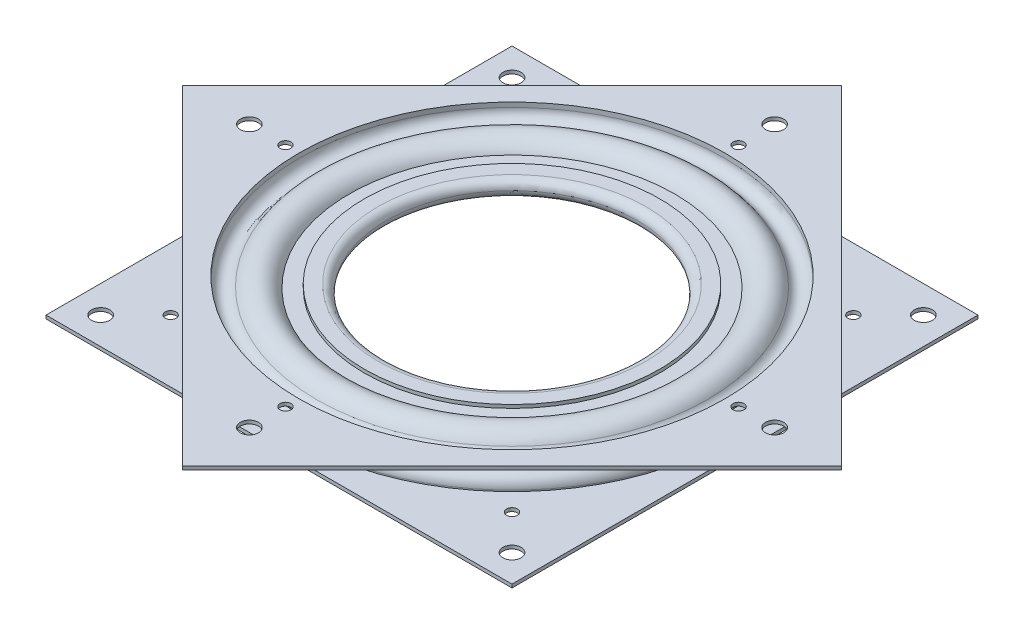
from build123d import *

# Parameters (mm, degrees)
SKETCH2_W                                 = 101.6
SKETCH2_H                                 = 101.6
SKETCH2_R                                 = 46.427290861
EXTRUDE1_DEPTH                            = 0.7366
SKETCH3_R                                 = 46.427290861
EXTRUDE2_DEPTH                            = 0.7366
CIRPATTERN1_COUNT                         = 4
SKETCH5_W                                 = 1.984375
SKETCH5_H                                 = 0.7366
F_5_32_0_156250_DIAMETER_HOLE1_AT_2_COUNT = 2
F_5_32_0_156250_DIAMETER_HOLE1_AT_2_PITCH = 89.6874
F_5_32_0_156250_DIAMETER_HOLE1_AT_3_COUNT = 2
F_5_32_0_156250_DIAMETER_HOLE1_AT_3_PITCH = 89.6874
F_5_32_0_156250_DIAMETER_HOLE1_AT_4_COUNT = 2
F_5_32_0_156250_DIAMETER_HOLE1_AT_4_PITCH = 126.837137454
SKETCH7_W                                 = 1.984375
SKETCH7_H                                 = 8.128
F_5_32_0_156250_DIAMETER_HOLE2_AT_2_COUNT = 2
F_5_32_0_156250_DIAMETER_HOLE2_AT_2_PITCH = 80.9752
F_5_32_0_156250_DIAMETER_HOLE2_AT_3_COUNT = 2
F_5_32_0_156250_DIAMETER_HOLE2_AT_3_PITCH = 114.516226056
F_5_32_0_156250_DIAMETER_HOLE2_AT_4_COUNT = 2
F_5_32_0_156250_DIAMETER_HOLE2_AT_4_PITCH = 80.9752
SKETCH9_W                                 = 1.190625
SKETCH9_H                                 = 0.7366
F_3_32_0_093750_DIAMETER_HOLE1_AT_2_COUNT = 2
F_3_32_0_093750_DIAMETER_HOLE1_AT_2_PITCH = 69.85
F_3_32_0_093750_DIAMETER_HOLE1_AT_3_COUNT = 2
F_3_32_0_093750_DIAMETER_HOLE1_AT_3_PITCH = 98.782817332
F_3_32_0_093750_DIAMETER_HOLE1_AT_4_COUNT = 2
F_3_32_0_093750_DIAMETER_HOLE1_AT_4_PITCH = 69.85
F_3_32_0_093750_DIAMETER_HOLE2_AT_2_COUNT = 2
F_3_32_0_093750_DIAMETER_HOLE2_AT_2_PITCH = 74.422
F_3_32_0_093750_DIAMETER_HOLE2_AT_3_COUNT = 2
F_3_32_0_093750_DIAMETER_HOLE2_AT_3_PITCH = 105.248601739
F_3_32_0_093750_DIAMETER_HOLE2_AT_4_COUNT = 2
F_3_32_0_093750_DIAMETER_HOLE2_AT_4_PITCH = 74.422


with BuildPart() as part:
    # Sketch1 → Revolve-Thin4 (revolve)
    with BuildSketch(Plane.XY, mode=Mode.PRIVATE) as revolve_thin4_sk:
        with BuildLine():
            Line((32.19552446, 1.778), (29.21, 1.778))
            ThreePointArc((29.21, 1.778), (27.432, 0), (29.21, -1.778))
            Line((29.21, -1.778), (35.18104892, -1.778))
            ThreePointArc((35.18104892, -1.778), (38.567175582, -4.788771381), (42.635527241, -2.794))
            ThreePointArc((42.635527241, -2.794), (44.921211161, -1.847238721), (46.427290861, -3.81))
            Line((46.427290861, -3.81), (46.427290861, -4.826))
            Line((46.427290861, -4.826), (50.8, -4.826))
            Line((50.8, -4.826), (50.8, -4.0894))
            Line((50.8, -4.0894), (47.163890861, -4.0894))
            Line((47.163890861, -4.0894), (47.163890861, -3.81))
            ThreePointArc((47.163890861, -3.81), (45.11185727, -1.135737757), (41.997612929, -2.4257))
            ThreePointArc((41.997612929, -2.4257), (38.390625346, -4.00937161), (35.800351285, -1.0414))
            Line((35.800351285, -1.0414), (29.21, -1.0414))
            ThreePointArc((29.21, -1.0414), (28.1686, 0), (29.21, 1.0414))
            Line((29.21, 1.0414), (32.19552446, 1.0414))
            Line((32.19552446, 1.0414), (32.19552446, 1.778))
        make_face()
    revolve(revolve_thin4_sk.sketch.rotate(Axis((0, 21.71272626, 0), (0, -1, 0)), 90), axis=Axis((0, 21.71272626, 0), (0, -1, 0)))

    # Sketch2 → Extrude1 (add)
    with BuildSketch(Plane.XZ.offset(4.826)):
        Rectangle(SKETCH2_W, SKETCH2_H)
        with Locations(Location((0, 0, 0), (0, 0, 90))):
            Circle(SKETCH2_R, mode=Mode.SUBTRACT)
    extrude(amount=-EXTRUDE1_DEPTH)

    # Sketch5 → 5_32 _0.156250_ Diameter Hole1 (revolve, cut)
    with BuildSketch(Plane(origin=(44.8437, -4.0894, -44.8437), x_dir=(0, 0, 1), z_dir=(1, 0, 0))):
        with Locations((0.9921875, 0.3683)):
            Rectangle(SKETCH5_W, SKETCH5_H)
    f_5_32_0_156250_diameter_hole1 = revolve(axis=Axis((44.8437, 2.2606, -44.8437), (0, -1, 0)), mode=Mode.SUBTRACT)

    # 5_32 _0.156250_ Diameter Hole1 at 2: 5_32 _0.156250_ Diameter Hole1 ×2
    with Locations(*[(0, 0, i * F_5_32_0_156250_DIAMETER_HOLE1_AT_2_PITCH) for i in range(1, F_5_32_0_156250_DIAMETER_HOLE1_AT_2_COUNT)]):
        add(f_5_32_0_156250_diameter_hole1, mode=Mode.SUBTRACT)

    # 5_32 _0.156250_ Diameter Hole1 at 3: 5_32 _0.156250_ Diameter Hole1 ×2
    with Locations(*[(-i * F_5_32_0_156250_DIAMETER_HOLE1_AT_3_PITCH, 0, 0) for i in range(1, F_5_32_0_156250_DIAMETER_HOLE1_AT_3_COUNT)]):
        add(f_5_32_0_156250_diameter_hole1, mode=Mode.SUBTRACT)

    # 5_32 _0.156250_ Diameter Hole1 at 4: 5_32 _0.156250_ Diameter Hole1 ×2
    with Locations(*[Vector(-0.7071067811865476, 0, 0.7071067811865476) * (i * F_5_32_0_156250_DIAMETER_HOLE1_AT_4_PITCH) for i in range(1, F_5_32_0_156250_DIAMETER_HOLE1_AT_4_COUNT)]):
        add(f_5_32_0_156250_diameter_hole1, mode=Mode.SUBTRACT)

    # Sketch11 → 3_32 _0.093750_ Diameter Hole2 (revolve, cut)
    with BuildSketch(Plane(origin=(37.211, -4.0894, 37.211), x_dir=(0, 0, 1), z_dir=(1, 0, 0))):
        Polygon((0, 0), (0, 26.115399675), (1.190625, 25.4), (1.190625, 0), align=None)
    f_3_32_0_093750_diameter_hole2 = revolve(axis=Axis((37.211, 2.2606, 37.211), (0, -1, 0)), mode=Mode.SUBTRACT)

    # 3_32 _0.093750_ Diameter Hole2 at 2: 3_32 _0.093750_ Diameter Hole2 ×2
    with Locations(*[(-i * F_3_32_0_093750_DIAMETER_HOLE2_AT_2_PITCH, 0, 0) for i in range(1, F_3_32_0_093750_DIAMETER_HOLE2_AT_2_COUNT)]):
        add(f_3_32_0_093750_diameter_hole2, mode=Mode.SUBTRACT)

    # 3_32 _0.093750_ Diameter Hole2 at 3: 3_32 _0.093750_ Diameter Hole2 ×2
    with Locations(*[Vector(-0.7071067811865476, 0, -0.7071067811865476) * (i * F_3_32_0_093750_DIAMETER_HOLE2_AT_3_PITCH) for i in range(1, F_3_32_0_093750_DIAMETER_HOLE2_AT_3_COUNT)]):
        add(f_3_32_0_093750_diameter_hole2, mode=Mode.SUBTRACT)

    # 3_32 _0.093750_ Diameter Hole2 at 4: 3_32 _0.093750_ Diameter Hole2 ×2
    with Locations(*[(0, 0, -i * F_3_32_0_093750_DIAMETER_HOLE2_AT_4_PITCH) for i in range(1, F_3_32_0_093750_DIAMETER_HOLE2_AT_4_COUNT)]):
        add(f_3_32_0_093750_diameter_hole2, mode=Mode.SUBTRACT)


with BuildPart() as body_2:
    # Sketch1_5 → Revolve-Thin5 (revolve)
    with BuildSketch(Plane.XY, mode=Mode.PRIVATE) as revolve_thin5_sk:
        with BuildLine():
            Line((29.21, 1.0414), (35.474043872, 1.0414))
            ThreePointArc((35.474043872, 1.0414), (38.986340067, 3.299931105), (42.635527241, 1.27))
            ThreePointArc((42.635527241, 1.27), (44.921211161, 0.323238721), (46.427290861, 2.286))
            Line((46.427290861, 2.286), (46.427290861, 3.302))
            Line((46.427290861, 3.302), (50.8, 3.302))
            Line((50.8, 3.302), (50.8, 2.5654))
            Line((50.8, 2.5654), (47.163890861, 2.5654))
            Line((47.163890861, 2.5654), (47.163890861, 2.286))
            ThreePointArc((47.163890861, 2.286), (45.11185727, -0.388262243), (41.997612929, 0.9017))
            ThreePointArc((41.997612929, 0.9017), (38.788408911, 2.54923464), (35.964249927, 0.3048))
            Line((35.964249927, 0.3048), (29.21, 0.3048))
            Line((29.21, 0.3048), (29.21, 1.0414))
        make_face()
    revolve(revolve_thin5_sk.sketch.rotate(Axis((0, 21.71272626, 0), (0, -1, 0)), 90), axis=Axis((0, 21.71272626, 0), (0, -1, 0)))

    # Sketch3 → Extrude2 (add)
    with BuildSketch(Plane(origin=(0, 3.302, 0), x_dir=(-1, 0, 0), z_dir=(0, 1, 0))):
        Polygon((0, -71.842048969), (71.842048969, 0), (0, 71.842048969), (-71.842048969, 0), align=None)
        with Locations(Location((0, 0, 0), (0, 0, 90))):
            Circle(SKETCH3_R, mode=Mode.SUBTRACT)
    extrude(amount=-EXTRUDE2_DEPTH)

    # Sketch7 → 5_32 _0.156250_ Diameter Hole2 (revolve, cut)
    with BuildSketch(Plane(origin=(57.258113028, 3.302, 0), x_dir=(0, 0, 1), z_dir=(1, 0, 0))):
        with Locations((0.9921875, 4.064)):
            Rectangle(SKETCH7_W, SKETCH7_H)
    f_5_32_0_156250_diameter_hole2 = revolve(axis=Axis((57.258113028, 9.652, 0), (0, -1, 0)), mode=Mode.SUBTRACT)

    # 5_32 _0.156250_ Diameter Hole2 at 2: 5_32 _0.156250_ Diameter Hole2 ×2
    with Locations(*[Vector(-0.7071067811865475, 0, -0.7071067811865476) * (i * F_5_32_0_156250_DIAMETER_HOLE2_AT_2_PITCH) for i in range(1, F_5_32_0_156250_DIAMETER_HOLE2_AT_2_COUNT)]):
        add(f_5_32_0_156250_diameter_hole2, mode=Mode.SUBTRACT)

    # 5_32 _0.156250_ Diameter Hole2 at 3: 5_32 _0.156250_ Diameter Hole2 ×2
    with Locations(*[(-i * F_5_32_0_156250_DIAMETER_HOLE2_AT_3_PITCH, 0, 0) for i in range(1, F_5_32_0_156250_DIAMETER_HOLE2_AT_3_COUNT)]):
        add(f_5_32_0_156250_diameter_hole2, mode=Mode.SUBTRACT)

    # 5_32 _0.156250_ Diameter Hole2 at 4: 5_32 _0.156250_ Diameter Hole2 ×2
    with Locations(*[Vector(-0.7071067811865475, 0, 0.7071067811865476) * (i * F_5_32_0_156250_DIAMETER_HOLE2_AT_4_PITCH) for i in range(1, F_5_32_0_156250_DIAMETER_HOLE2_AT_4_COUNT)]):
        add(f_5_32_0_156250_diameter_hole2, mode=Mode.SUBTRACT)

    # Sketch9 → 3_32 _0.093750_ Diameter Hole1 (revolve, cut)
    with BuildSketch(Plane(origin=(0, 3.302, -49.391408666), x_dir=(0, 0, 1), z_dir=(1, 0, 0))):
        with Locations((0.5953125, 0.3683)):
            Rectangle(SKETCH9_W, SKETCH9_H)
    f_3_32_0_093750_diameter_hole1 = revolve(axis=Axis((0, 9.652, -49.391408666), (0, -1, 0)), mode=Mode.SUBTRACT)

    # 3_32 _0.093750_ Diameter Hole1 at 2: 3_32 _0.093750_ Diameter Hole1 ×2
    with Locations(*[Vector(0.7071067811865477, 0, 0.7071067811865475) * (i * F_3_32_0_093750_DIAMETER_HOLE1_AT_2_PITCH) for i in range(1, F_3_32_0_093750_DIAMETER_HOLE1_AT_2_COUNT)]):
        add(f_3_32_0_093750_diameter_hole1, mode=Mode.SUBTRACT)

    # 3_32 _0.093750_ Diameter Hole1 at 3: 3_32 _0.093750_ Diameter Hole1 ×2
    with Locations(*[(0, 0, i * F_3_32_0_093750_DIAMETER_HOLE1_AT_3_PITCH) for i in range(1, F_3_32_0_093750_DIAMETER_HOLE1_AT_3_COUNT)]):
        add(f_3_32_0_093750_diameter_hole1, mode=Mode.SUBTRACT)

    # 3_32 _0.093750_ Diameter Hole1 at 4: 3_32 _0.093750_ Diameter Hole1 ×2
    with Locations(*[Vector(-0.7071067811865474, 0, 0.7071067811865477) * (i * F_3_32_0_093750_DIAMETER_HOLE1_AT_4_PITCH) for i in range(1, F_3_32_0_093750_DIAMETER_HOLE1_AT_4_COUNT)]):
        add(f_3_32_0_093750_diameter_hole1, mode=Mode.SUBTRACT)


with BuildPart() as body_3:
    # Sketch4 → Revolve1 (revolve)
    with BuildSketch(Plane.XY):
        with BuildLine():
            Line((39.116, 2.5146), (39.116, -4.0386))
            ThreePointArc((39.116, -4.0386), (42.3926, -0.762), (39.116, 2.5146))
        make_face()
    revolve(axis=Axis((39.116, 2.837450101, 0), (0, -1, 0)))


with BuildPart() as cirpattern1_1:
    # CirPattern1: pattern copy
    add(body_3.part.rotate(Axis((0, 0, 0), (0, 1, 0)), 1 * 360 / CIRPATTERN1_COUNT))


with BuildPart() as cirpattern1_2:
    # CirPattern1: pattern copy
    add(body_3.part.rotate(Axis((0, 0, 0), (0, 1, 0)), 2 * 360 / CIRPATTERN1_COUNT))


with BuildPart() as cirpattern1_3:
    # CirPattern1: pattern copy
    add(body_3.part.rotate(Axis((0, 0, 0), (0, 1, 0)), 3 * 360 / CIRPATTERN1_COUNT))


solid = Compound([part.part, body_2.part, body_3.part, cirpattern1_1.part, cirpattern1_2.part, cirpattern1_3.part])
